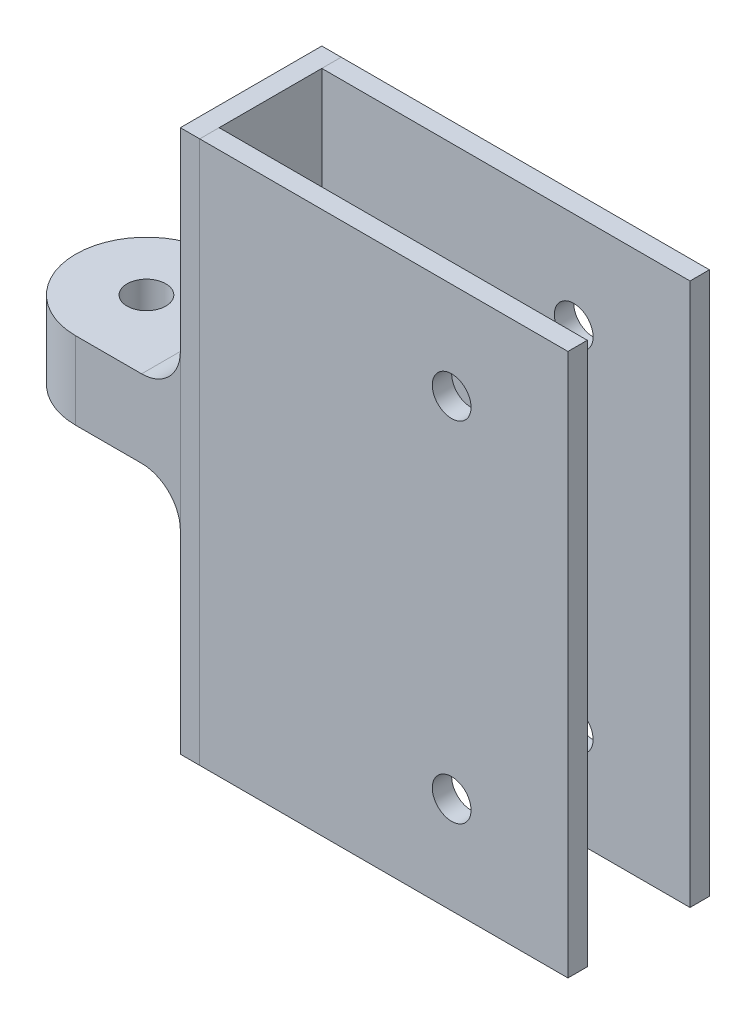
from build123d import *

# Parameters (mm, degrees)
BOSS_EXTRUDE1_DEPTH      = 20
BOSS_EXTRUDE2_DEPTH      = 60
BOSS_EXTRUDE3_DEPTH      = 60
M8_CLEARANCE_HOLE1_D     = 10
M8_CLEARANCE_HOLE2_D     = 10
FILLET2_R                = 10
SPLIT1_SURFACE_1_1_BACK  = 206.012
SPLIT1_SURFACE_1_1_DEPTH = 412.024
SPLIT1_SURFACE_1_2_BACK  = 206.012
SPLIT1_SURFACE_1_2_DEPTH = 412.024
SPLIT1_SURFACE_2_3_BACK  = 206.012
SPLIT1_SURFACE_2_3_DEPTH = 412.024
SPLIT1_SURFACE_2_4_BACK  = 206.012
SPLIT1_SURFACE_2_4_DEPTH = 412.024
SPLIT1_SURFACE_3_5_BACK  = 206.012
SPLIT1_SURFACE_3_5_DEPTH = 412.024
SPLIT1_SURFACE_3_6_BACK  = 206.012
SPLIT1_SURFACE_3_6_DEPTH = 412.024


with BuildPart() as part:
    # Sketch1 → Boss-Extrude1 (new body)
    with BuildSketch(Plane(origin=(0, 0, 0), x_dir=(1, 0, 0), z_dir=(0, 1, 0))):
        with BuildLine():
            Line((5, 5), (5, 31.5))
            Line((5, 31.5), (100, 31.5))
            Line((100, 31.5), (100, 36.5))
            Line((100, 36.5), (-27, 36.5))
            ThreePointArc((-27, 36.5), (-45.25, 18.25), (-27, 0))
            Line((-27, 0), (100, 0))
            Line((100, 0), (100, 5))
            Line((100, 5), (5, 5))
        make_face()
    extrude(amount=BOSS_EXTRUDE1_DEPTH)

    # Sketch2 → Boss-Extrude2 (add)
    with BuildSketch(Plane(origin=(0, 20, 0), x_dir=(1, 0, 0), z_dir=(0, 1, 0))):
        Polygon((0, 0), (100, 0), (100, 5), (5, 5), (5, 31.5), (100, 31.5), (100, 36.5), (0, 36.5), align=None)
    extrude(amount=BOSS_EXTRUDE2_DEPTH)

    # Sketch3 → Boss-Extrude3 (add)
    with BuildSketch(Plane.XZ):
        Polygon((0, -36.5), (100, -36.5), (100, -31.5), (5, -31.5), (5, -5), (100, -5), (100, 0), (0, 0), align=None)
    extrude(amount=BOSS_EXTRUDE3_DEPTH)

    # M8 Clearance Hole1 (through all)
    with Locations(Plane(origin=(0, 20, 0), x_dir=(1, 0, 0), z_dir=(0, 1, 0))):
        with Locations((-27, 18.25)):
            Hole(M8_CLEARANCE_HOLE1_D / 2)

    # M8 Clearance Hole2 (through all)
    with Locations(Plane.XY):
        with Locations((70, 55), (70, -35)):
            Hole(M8_CLEARANCE_HOLE2_D / 2)

    # Fillet2
    fillet2_edges = [part.edges().sort_by_distance(p)[0] for p in [
        (0, 20, -18.25),
        (0, 0, -18.25),
    ]]
    fillet(fillet2_edges, radius=FILLET2_R)


with BuildPart() as body_2:
    # Split1: the piece behind the surface
    add(part.part)
    # Split1 surface 1: a surface, the sketch's curves swept straight by 412.024 mm
    with BuildLine(Plane(origin=(0, 0, 0), x_dir=(1, 0, 0), z_dir=(0, 1, 0)).offset(-SPLIT1_SURFACE_1_1_BACK), mode=Mode.PRIVATE) as split1_surface_1_1_path:
        Line((0, 36.5), (0, 0))
    split1_surface_1_1 = Shell.extrude(split1_surface_1_1_path.wire(), (0 * SPLIT1_SURFACE_1_1_DEPTH, 1 * SPLIT1_SURFACE_1_1_DEPTH, 0 * SPLIT1_SURFACE_1_1_DEPTH))
    split(bisect_by=split1_surface_1_1, keep=Keep.BOTTOM)


with BuildPart() as part_1:
    add(part.part)

    # Split1: split by a surface, the side it looks to stays
    # Split1 surface 1: a surface, the sketch's curves swept straight by 412.024 mm
    with BuildLine(Plane(origin=(0, 0, 0), x_dir=(1, 0, 0), z_dir=(0, 1, 0)).offset(-SPLIT1_SURFACE_1_2_BACK), mode=Mode.PRIVATE) as split1_surface_1_2_path:
        Line((0, 36.5), (0, 0))
    split1_surface_1_2 = Shell.extrude(split1_surface_1_2_path.wire(), (0 * SPLIT1_SURFACE_1_2_DEPTH, 1 * SPLIT1_SURFACE_1_2_DEPTH, 0 * SPLIT1_SURFACE_1_2_DEPTH))
    split(bisect_by=split1_surface_1_2, keep=Keep.TOP)


with BuildPart() as body_3:
    # Split1 2: the piece behind the surface
    add(part_1.part)
    # Split1 surface 2: a surface, the sketch's curves swept straight by 412.024 mm
    with BuildLine(Plane(origin=(0, 0, 0), x_dir=(1, 0, 0), z_dir=(0, 1, 0)).offset(-SPLIT1_SURFACE_2_3_BACK), mode=Mode.PRIVATE) as split1_surface_2_3_path:
        Line((5, 5), (5, 0))
    split1_surface_2_3 = Shell.extrude(split1_surface_2_3_path.wire(), (0 * SPLIT1_SURFACE_2_3_DEPTH, 1 * SPLIT1_SURFACE_2_3_DEPTH, 0 * SPLIT1_SURFACE_2_3_DEPTH))
    split(bisect_by=split1_surface_2_3, keep=Keep.BOTTOM)


with BuildPart() as part_2:
    add(part_1.part)

    # Split1 2: split by a surface, the side it looks to stays
    # Split1 surface 2: a surface, the sketch's curves swept straight by 412.024 mm
    with BuildLine(Plane(origin=(0, 0, 0), x_dir=(1, 0, 0), z_dir=(0, 1, 0)).offset(-SPLIT1_SURFACE_2_4_BACK), mode=Mode.PRIVATE) as split1_surface_2_4_path:
        Line((5, 5), (5, 0))
    split1_surface_2_4 = Shell.extrude(split1_surface_2_4_path.wire(), (0 * SPLIT1_SURFACE_2_4_DEPTH, 1 * SPLIT1_SURFACE_2_4_DEPTH, 0 * SPLIT1_SURFACE_2_4_DEPTH))
    split(bisect_by=split1_surface_2_4, keep=Keep.TOP)


with BuildPart() as body_4_2:
    # Split1 3 body 3: the piece behind the surface
    add(body_3.part)
    # Split1 surface 3: a surface, the sketch's curves swept straight by 412.024 mm
    with BuildLine(Plane(origin=(0, 0, 0), x_dir=(1, 0, 0), z_dir=(0, 1, 0)).offset(-SPLIT1_SURFACE_3_5_BACK), mode=Mode.PRIVATE) as split1_surface_3_5_path:
        Line((5, 31.5), (5, 36.5))
    split1_surface_3_5 = Shell.extrude(split1_surface_3_5_path.wire(), (0 * SPLIT1_SURFACE_3_5_DEPTH, 1 * SPLIT1_SURFACE_3_5_DEPTH, 0 * SPLIT1_SURFACE_3_5_DEPTH))
    split(bisect_by=split1_surface_3_5, keep=Keep.BOTTOM)


with BuildPart() as body_3_1:
    add(body_3.part)

    # Split1 3 body 3: split by a surface, the side it looks to stays
    # Split1 surface 3: a surface, the sketch's curves swept straight by 412.024 mm
    with BuildLine(Plane(origin=(0, 0, 0), x_dir=(1, 0, 0), z_dir=(0, 1, 0)).offset(-SPLIT1_SURFACE_3_6_BACK), mode=Mode.PRIVATE) as split1_surface_3_6_path:
        Line((5, 31.5), (5, 36.5))
    split1_surface_3_6 = Shell.extrude(split1_surface_3_6_path.wire(), (0 * SPLIT1_SURFACE_3_6_DEPTH, 1 * SPLIT1_SURFACE_3_6_DEPTH, 0 * SPLIT1_SURFACE_3_6_DEPTH))
    split(bisect_by=split1_surface_3_6, keep=Keep.TOP)


solid = Compound([body_2.part, part_2.part, body_4_2.part, body_3_1.part])
